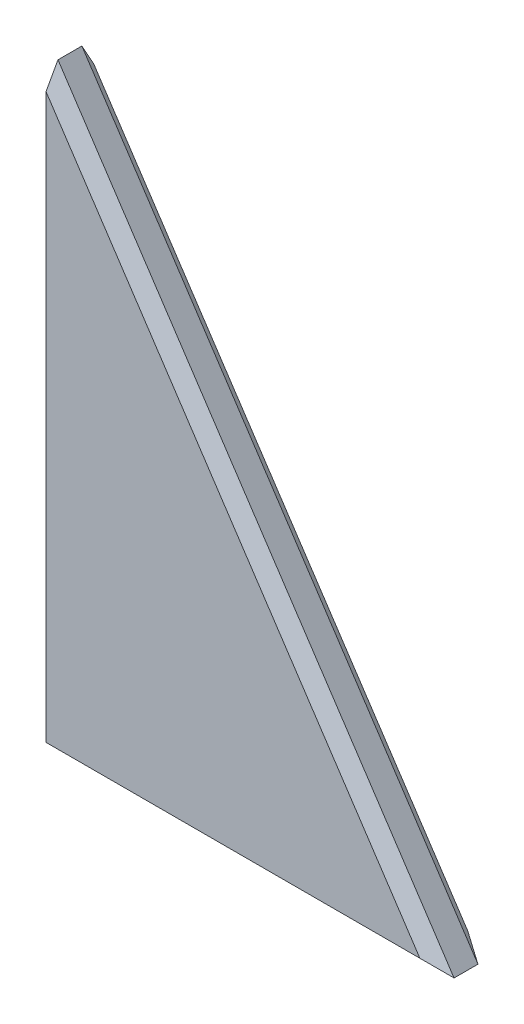
from build123d import *

# Parameters (mm, degrees)
EXTRUDE1_DEPTH = 2.54
CHAMFER1_SIZE  = 1.27


with BuildPart() as part:
    # Sketch1 → Extrude1 (new body, symmetric)
    with BuildSketch(Plane.XY):
        Polygon((0, 63.5), (42.121134838, 0), (0, 0), align=None)
    extrude(amount=EXTRUDE1_DEPTH, both=True)

    # Chamfer1
    chamfer1_edges = [part.edges().sort_by_distance(p)[0] for p in [
        (21.060567419, 31.75, 2.54),
        (21.060567419, 31.75, -2.54),
        (21.060567419, 0, -2.54),
        (21.060567419, 0, 2.54),
    ]]
    chamfer(chamfer1_edges, length=CHAMFER1_SIZE)


solid = part.part
